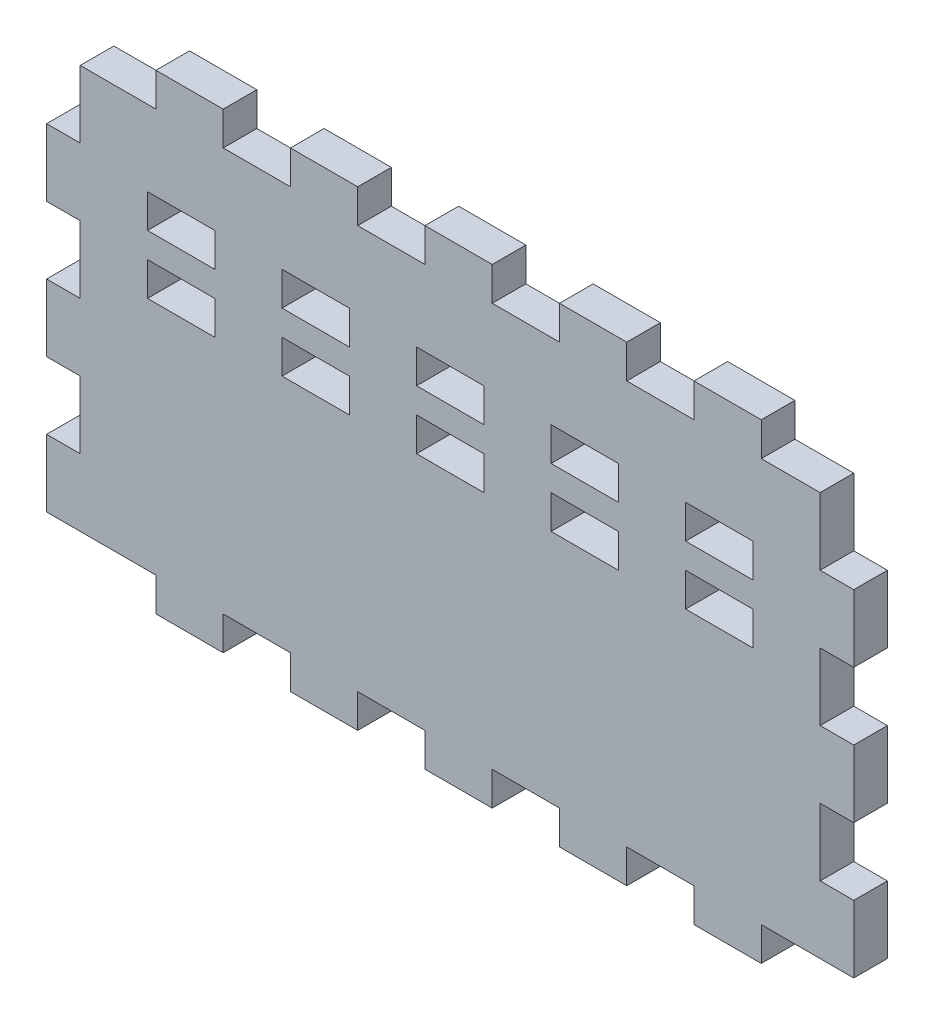
from build123d import *

# Parameters (mm, degrees)
SKETCH1_W               = 279.4
SKETCH1_H               = 152.4
BOSS_EXTRUDE1_DEPTH     = 12.7
SKETCH2_W               = 25.4
SKETCH2_H               = 12.7
BOSS_EXTRUDE2_DEPTH     = 12.7
LPATTERN1_COUNT         = 5
LPATTERN1_PITCH         = 50.8
MIRROR1_COPY_1_SKETCH_W = 25.4
MIRROR1_COPY_1_SKETCH_H = 12.7
MIRROR1_COPY_1_DEPTH    = 12.7
MIRROR1_COPY_2_SKETCH_W = 25.4
MIRROR1_COPY_2_SKETCH_H = 12.7
MIRROR1_COPY_2_DEPTH    = 12.7
MIRROR1_COPY_3_SKETCH_W = 25.4
MIRROR1_COPY_3_SKETCH_H = 12.7
MIRROR1_COPY_3_DEPTH    = 12.7
MIRROR1_COPY_4_SKETCH_W = 25.4
MIRROR1_COPY_4_SKETCH_H = 12.7
MIRROR1_COPY_4_DEPTH    = 12.7
SKETCH3_W               = 12.7
SKETCH3_H               = 25.4
BOSS_EXTRUDE3_DEPTH     = 12.7
LPATTERN2_COUNT         = 3
LPATTERN2_PITCH         = 50.8
MIRROR2_COPY_1_SKETCH_W = 12.7
MIRROR2_COPY_1_SKETCH_H = 25.4
MIRROR2_COPY_1_DEPTH    = 12.7
MIRROR2_COPY_2_SKETCH_W = 12.7
MIRROR2_COPY_2_SKETCH_H = 25.4
MIRROR2_COPY_2_DEPTH    = 12.7
SKETCH4_W               = 25.4
SKETCH4_H               = 12.7
CUT_EXTRUDE1_DEPTH      = 13.7
LPATTERN3_COUNT         = 5
LPATTERN3_PITCH         = 50.8


with BuildPart() as part:
    # Sketch1 → Boss-Extrude1 (new body)
    with BuildSketch(Plane.XY):
        Rectangle(SKETCH1_W, SKETCH1_H)
    extrude(amount=BOSS_EXTRUDE1_DEPTH)

    # Sketch2 → Boss-Extrude2 (add)
    with BuildSketch(Plane.XZ.offset(76.2)):
        with Locations((-98.425, 6.35)):
            Rectangle(SKETCH2_W, SKETCH2_H)
    boss_extrude2 = extrude(amount=BOSS_EXTRUDE2_DEPTH)

    # LPattern1: Boss-Extrude2 ×5
    with Locations(*[(i * LPATTERN1_PITCH, 0, 0) for i in range(1, LPATTERN1_COUNT)]):
        add(boss_extrude2)

    # Mirror1: Boss-Extrude2 across plane
    add(boss_extrude2.mirror(Plane.ZX))

    # Mirror1 copy 1 sketch → Mirror1 copy 1 (add)
    with BuildSketch(Plane(origin=(50.8, 76.2, 0), x_dir=(1, 0, 0), z_dir=(0, 1, 0))):
        with Locations((-98.425, -6.35)):
            Rectangle(MIRROR1_COPY_1_SKETCH_W, MIRROR1_COPY_1_SKETCH_H)
    extrude(amount=MIRROR1_COPY_1_DEPTH)

    # Mirror1 copy 2 sketch → Mirror1 copy 2 (add)
    with BuildSketch(Plane(origin=(101.6, 76.2, 0), x_dir=(1, 0, 0), z_dir=(0, 1, 0))):
        with Locations((-98.425, -6.35)):
            Rectangle(MIRROR1_COPY_2_SKETCH_W, MIRROR1_COPY_2_SKETCH_H)
    extrude(amount=MIRROR1_COPY_2_DEPTH)

    # Mirror1 copy 3 sketch → Mirror1 copy 3 (add)
    with BuildSketch(Plane(origin=(152.4, 76.2, 0), x_dir=(1, 0, 0), z_dir=(0, 1, 0))):
        with Locations((-98.425, -6.35)):
            Rectangle(MIRROR1_COPY_3_SKETCH_W, MIRROR1_COPY_3_SKETCH_H)
    extrude(amount=MIRROR1_COPY_3_DEPTH)

    # Mirror1 copy 4 sketch → Mirror1 copy 4 (add)
    with BuildSketch(Plane(origin=(203.2, 76.2, 0), x_dir=(1, 0, 0), z_dir=(0, 1, 0))):
        with Locations((-98.425, -6.35)):
            Rectangle(MIRROR1_COPY_4_SKETCH_W, MIRROR1_COPY_4_SKETCH_H)
    extrude(amount=MIRROR1_COPY_4_DEPTH)

    # Sketch3 → Boss-Extrude3 (add)
    with BuildSketch(Plane(origin=(139.7, 0, 0), x_dir=(0, 0, -1), z_dir=(1, 0, 0))):
        with Locations((-6.35, -63.5)):
            Rectangle(SKETCH3_W, SKETCH3_H)
    boss_extrude3 = extrude(amount=BOSS_EXTRUDE3_DEPTH)

    # LPattern2: Boss-Extrude3 ×3
    with Locations(*[(0, i * LPATTERN2_PITCH, 0) for i in range(1, LPATTERN2_COUNT)]):
        add(boss_extrude3)

    # Mirror2: Boss-Extrude3 across plane
    add(boss_extrude3.mirror(Plane(origin=(0, 0, 0), x_dir=(0, 0, 1), z_dir=(1, 0, 0))))

    # Mirror2 copy 1 sketch → Mirror2 copy 1 (add)
    with BuildSketch(Plane(origin=(-139.7, 50.8, 0), x_dir=(0, 0, -1), z_dir=(-1, 0, 0))):
        with Locations((-6.35, 63.5)):
            Rectangle(MIRROR2_COPY_1_SKETCH_W, MIRROR2_COPY_1_SKETCH_H)
    extrude(amount=MIRROR2_COPY_1_DEPTH)

    # Mirror2 copy 2 sketch → Mirror2 copy 2 (add)
    with BuildSketch(Plane(origin=(-139.7, 101.6, 0), x_dir=(0, 0, -1), z_dir=(-1, 0, 0))):
        with Locations((-6.35, 63.5)):
            Rectangle(MIRROR2_COPY_2_SKETCH_W, MIRROR2_COPY_2_SKETCH_H)
    extrude(amount=MIRROR2_COPY_2_DEPTH)

    # Sketch4 → Cut-Extrude1 (cut, through all)
    with BuildSketch(Plane.XY.offset(12.7)):
        with Locations((-101.6, 19.05)):
            Rectangle(SKETCH4_W, SKETCH4_H)
        with Locations((-101.6, 41.275)):
            Rectangle(SKETCH4_W, SKETCH4_H)
    cut_extrude1 = extrude(amount=-CUT_EXTRUDE1_DEPTH, mode=Mode.SUBTRACT)

    # LPattern3: Cut-Extrude1 ×5
    with Locations(*[(i * LPATTERN3_PITCH, 0, 0) for i in range(1, LPATTERN3_COUNT)]):
        add(cut_extrude1, mode=Mode.SUBTRACT)


solid = part.part
